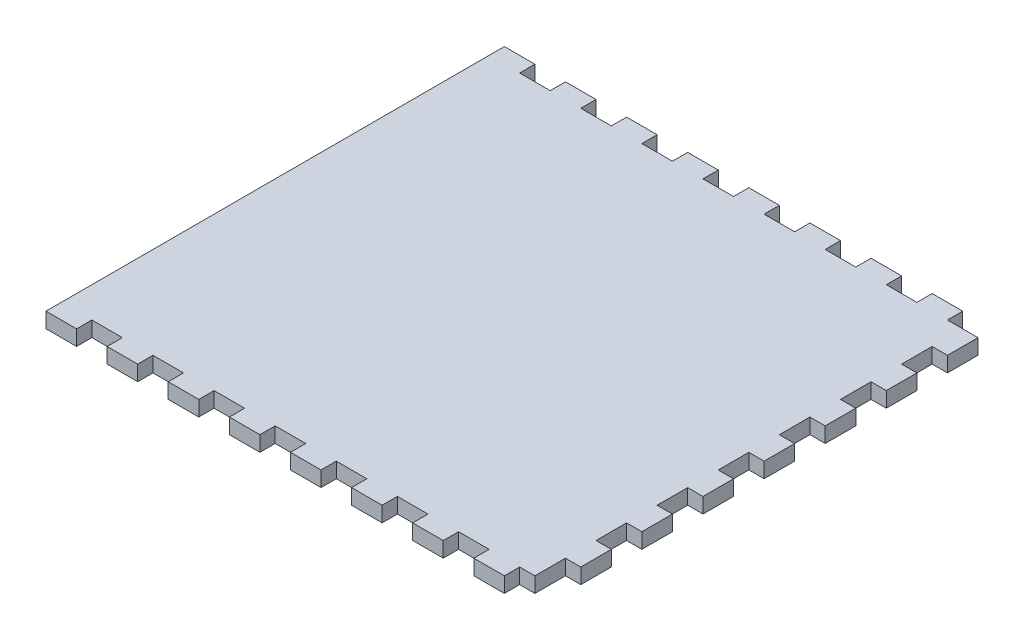
from build123d import *

# Parameters (mm, degrees)
SKETCH1_W               = 203.2
SKETCH1_H               = 190.5
BOSS_EXTRUDE1_DEPTH     = 6.35
SKETCH2_W               = 12.7
SKETCH2_H               = 6.35
CUT_EXTRUDE1_DEPTH      = 7.35
LPATTERN1_COUNT         = 8
LPATTERN1_PITCH         = 25.4
MIRROR1_COPY_1_SKETCH_W = 12.7
MIRROR1_COPY_1_SKETCH_H = 6.35
MIRROR1_COPY_1_DEPTH    = 7.35
MIRROR1_COPY_2_SKETCH_W = 12.7
MIRROR1_COPY_2_SKETCH_H = 6.35
MIRROR1_COPY_2_DEPTH    = 7.35
MIRROR1_COPY_3_SKETCH_W = 12.7
MIRROR1_COPY_3_SKETCH_H = 6.35
MIRROR1_COPY_3_DEPTH    = 7.35
MIRROR1_COPY_4_SKETCH_W = 12.7
MIRROR1_COPY_4_SKETCH_H = 6.35
MIRROR1_COPY_4_DEPTH    = 7.35
MIRROR1_COPY_5_SKETCH_W = 12.7
MIRROR1_COPY_5_SKETCH_H = 6.35
MIRROR1_COPY_5_DEPTH    = 7.35
MIRROR1_COPY_6_SKETCH_W = 12.7
MIRROR1_COPY_6_SKETCH_H = 6.35
MIRROR1_COPY_6_DEPTH    = 7.35
MIRROR1_COPY_7_SKETCH_W = 12.7
MIRROR1_COPY_7_SKETCH_H = 6.35
MIRROR1_COPY_7_DEPTH    = 7.35
SKETCH4_W               = 6.35
SKETCH4_H               = 12.7
CUT_EXTRUDE2_DEPTH      = 7.35
LPATTERN2_COUNT         = 7
LPATTERN2_PITCH         = 25.4


with BuildPart() as part:
    # Sketch1 → Boss-Extrude1 (new body)
    with BuildSketch(Plane(origin=(0, 0, 0), x_dir=(1, 0, 0), z_dir=(0, 1, 0))):
        Rectangle(SKETCH1_W, SKETCH1_H)
    extrude(amount=BOSS_EXTRUDE1_DEPTH)

    # Sketch2 → Cut-Extrude1 (cut, through all)
    with BuildSketch(Plane.XZ):
        with Locations((-82.55, 92.075)):
            Rectangle(SKETCH2_W, SKETCH2_H)
    cut_extrude1 = extrude(amount=-CUT_EXTRUDE1_DEPTH, mode=Mode.SUBTRACT)

    # LPattern1: Cut-Extrude1 ×8
    with Locations(*[(i * LPATTERN1_PITCH, 0, 0) for i in range(1, LPATTERN1_COUNT)]):
        add(cut_extrude1, mode=Mode.SUBTRACT)

    # Mirror1: Cut-Extrude1 across plane
    add(cut_extrude1.mirror(Plane.XY), mode=Mode.SUBTRACT)

    # Mirror1 copy 1 sketch → Mirror1 copy 1 (cut, through all)
    with BuildSketch(Plane(origin=(25.4, 0, 0), x_dir=(1, 0, 0), z_dir=(0, -1, 0))):
        with Locations((-82.55, -92.075)):
            Rectangle(MIRROR1_COPY_1_SKETCH_W, MIRROR1_COPY_1_SKETCH_H)
    extrude(amount=-MIRROR1_COPY_1_DEPTH, mode=Mode.SUBTRACT)

    # Mirror1 copy 2 sketch → Mirror1 copy 2 (cut, through all)
    with BuildSketch(Plane(origin=(50.8, 0, 0), x_dir=(1, 0, 0), z_dir=(0, -1, 0))):
        with Locations((-82.55, -92.075)):
            Rectangle(MIRROR1_COPY_2_SKETCH_W, MIRROR1_COPY_2_SKETCH_H)
    extrude(amount=-MIRROR1_COPY_2_DEPTH, mode=Mode.SUBTRACT)

    # Mirror1 copy 3 sketch → Mirror1 copy 3 (cut, through all)
    with BuildSketch(Plane(origin=(76.2, 0, 0), x_dir=(1, 0, 0), z_dir=(0, -1, 0))):
        with Locations((-82.55, -92.075)):
            Rectangle(MIRROR1_COPY_3_SKETCH_W, MIRROR1_COPY_3_SKETCH_H)
    extrude(amount=-MIRROR1_COPY_3_DEPTH, mode=Mode.SUBTRACT)

    # Mirror1 copy 4 sketch → Mirror1 copy 4 (cut, through all)
    with BuildSketch(Plane(origin=(101.6, 0, 0), x_dir=(1, 0, 0), z_dir=(0, -1, 0))):
        with Locations((-82.55, -92.075)):
            Rectangle(MIRROR1_COPY_4_SKETCH_W, MIRROR1_COPY_4_SKETCH_H)
    extrude(amount=-MIRROR1_COPY_4_DEPTH, mode=Mode.SUBTRACT)

    # Mirror1 copy 5 sketch → Mirror1 copy 5 (cut, through all)
    with BuildSketch(Plane(origin=(127, 0, 0), x_dir=(1, 0, 0), z_dir=(0, -1, 0))):
        with Locations((-82.55, -92.075)):
            Rectangle(MIRROR1_COPY_5_SKETCH_W, MIRROR1_COPY_5_SKETCH_H)
    extrude(amount=-MIRROR1_COPY_5_DEPTH, mode=Mode.SUBTRACT)

    # Mirror1 copy 6 sketch → Mirror1 copy 6 (cut, through all)
    with BuildSketch(Plane(origin=(152.4, 0, 0), x_dir=(1, 0, 0), z_dir=(0, -1, 0))):
        with Locations((-82.55, -92.075)):
            Rectangle(MIRROR1_COPY_6_SKETCH_W, MIRROR1_COPY_6_SKETCH_H)
    extrude(amount=-MIRROR1_COPY_6_DEPTH, mode=Mode.SUBTRACT)

    # Mirror1 copy 7 sketch → Mirror1 copy 7 (cut, through all)
    with BuildSketch(Plane(origin=(177.8, 0, 0), x_dir=(1, 0, 0), z_dir=(0, -1, 0))):
        with Locations((-82.55, -92.075)):
            Rectangle(MIRROR1_COPY_7_SKETCH_W, MIRROR1_COPY_7_SKETCH_H)
    extrude(amount=-MIRROR1_COPY_7_DEPTH, mode=Mode.SUBTRACT)

    # Sketch4 → Cut-Extrude2 (cut, through all)
    with BuildSketch(Plane(origin=(0, 6.35, 0), x_dir=(1, 0, 0), z_dir=(0, 1, 0))):
        with Locations((98.425, 69.85)):
            Rectangle(SKETCH4_W, SKETCH4_H)
    cut_extrude2 = extrude(amount=-CUT_EXTRUDE2_DEPTH, mode=Mode.SUBTRACT)

    # LPattern2: Cut-Extrude2 ×7
    with Locations(*[(0, 0, i * LPATTERN2_PITCH) for i in range(1, LPATTERN2_COUNT)]):
        add(cut_extrude2, mode=Mode.SUBTRACT)


solid = part.part
